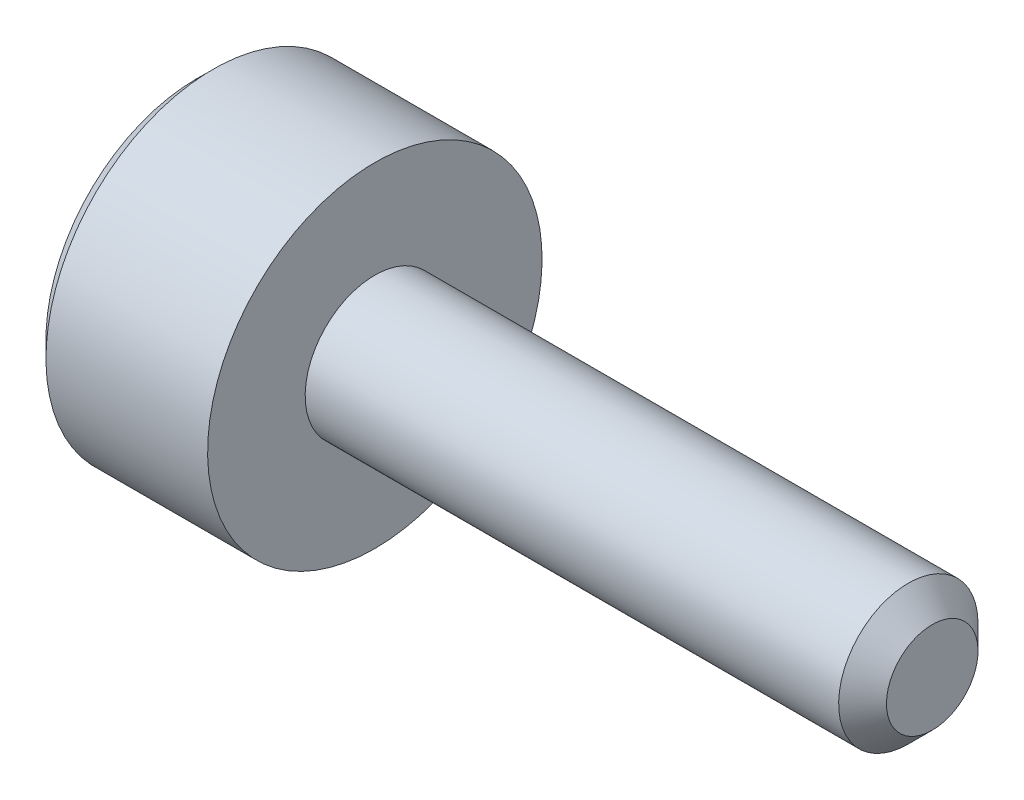
from build123d import *

# Parameters (mm, degrees)
CUT_EXTRUDE1_DEPTH = 0.64


with BuildPart() as part:
    # Sketch1 → Revolve1 (revolve)
    with BuildSketch(Plane.XY):
        Polygon((-1.6, 0), (-1.6, 1.35), (-1.45, 1.5), (0, 1.5), (0, 0.625), (4.7855, 0.625), (5, 0.4105), (5, 0), align=None)
    revolve(axis=Axis((5, 0, 0), (-1, 0, 0)))

    # Sketch2 → Cut-Extrude1 (cut)
    with BuildSketch(Plane(origin=(-1.6, 0, 0), x_dir=(0, 0, -1), z_dir=(1, 0, 0))):
        Polygon((-0.75, -0.433012702), (0, -0.866025404), (0.75, -0.433012702), (0.75, 0.433012702), (0, 0.866025404), (-0.75, 0.433012702), align=None)
    extrude(amount=CUT_EXTRUDE1_DEPTH, mode=Mode.SUBTRACT)


solid = part.part
